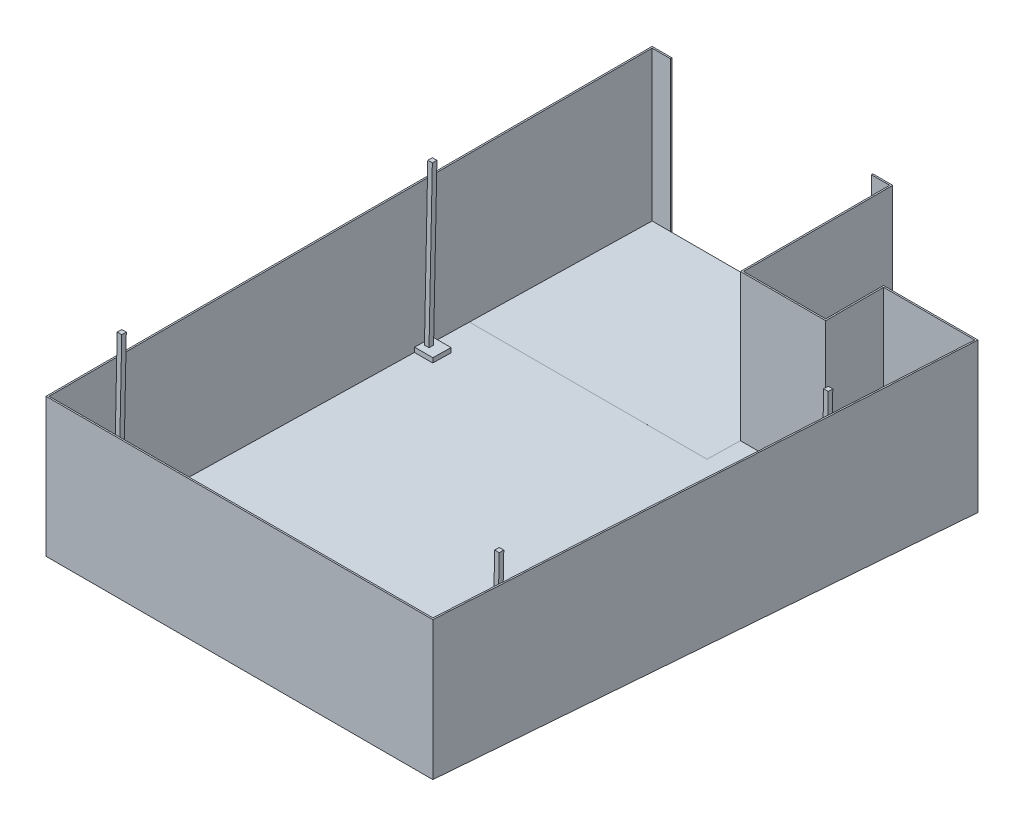
from build123d import *

# Parameters (mm, degrees)
BOSS_EXTRUDE2_DEPTH      = 2311.4
BOSS_EXTRUDE2_DEPTH_BACK = 254
CUT_EXTRUDE1_DEPTH       = 8907.603352569
SHELL3_T                 = -25.4
SKETCH5_W                = 304.8
SKETCH5_H                = 304.8
BOSS_EXTRUDE4_DEPTH      = 76.2
SKETCH6_W                = 76.2
SKETCH6_H                = 76.2
BOSS_EXTRUDE6_DEPTH      = 2643.378
BOSS_EXTRUDE7_DEPTH      = 0.0254
SKETCH8_W                = 3352.8
SKETCH8_H                = 2523.157553015
CUT_EXTRUDE2_DEPTH       = 25.4


with BuildPart() as part:
    # Sketch2 → Boss-Extrude2 (new, two sides)
    with BuildSketch(Plane(origin=(0, 0, 0), x_dir=(1, 0, 0), z_dir=(0, 1, 0))) as boss_extrude2_sk:
        Polygon((0, 5054.6), (0, -5054.6), (6451.6, -5054.6), (6959.6, 3530.6), (5384.8, 3530.6), (5384.8, 2565.4), (4013.2, 2565.4), (4013.2, 5054.6), align=None)
    extrude(amount=BOSS_EXTRUDE2_DEPTH)
    extrude(boss_extrude2_sk.sketch, amount=-BOSS_EXTRUDE2_DEPTH_BACK)

    # Sketch4 → Cut-Extrude1 (cut, through all)
    with BuildSketch(Plane.ZY):
        Polygon((5054.6, 0), (-5054.6, -211.757553015), (-5054.6, -254), (5054.6, -254), align=None)
    extrude(amount=-CUT_EXTRUDE1_DEPTH, mode=Mode.SUBTRACT)

    # Shell3
    shell3_openings = [part.faces().sort_by_distance(p)[0] for p in [
        (3193.672214635, 2311.4, 297.114656183),
    ]]
    offset(amount=SHELL3_T, openings=shell3_openings, kind=Kind.INTERSECTION)

    # Sketch5 → Boss-Extrude4 (add)
    with BuildSketch(Plane(origin=(0, -80.43791031, 1.684934026), x_dir=(1, 0, 0), z_dir=(0, 0.9997806834748456, -0.020942419883350005))):
        with Locations((177.8, -3961.817924984)):
            Rectangle(SKETCH5_W, SKETCH5_H)
        with Locations((177.8, 1219.782075016)):
            Rectangle(SKETCH5_W, SKETCH5_H)
        Polygon((6501.521028173, 1067.382075016), (6788.289480699, 1067.382075016), (6806.321028173, 1372.182075016), (6501.521028173, 1372.182075016), align=None)
        Polygon((6194.451826209, -4114.217924984), (6481.753173628, -4114.217924984), (6499.784721103, -3809.417924984), (6194.451826209, -3809.417924984), align=None)
    extrude(amount=BOSS_EXTRUDE4_DEPTH)

    # Sketch6 → Boss-Extrude6 (add)
    with BuildSketch(Plane(origin=(0, -4.254622229, 0.089121631), x_dir=(1, 0, 0), z_dir=(0, 0.9997806834748456, -0.02094241988335002))):
        with Locations((114.3, 1219.782075016)):
            Rectangle(SKETCH6_W, SKETCH6_H)
        with Locations((114.3, -3961.817924984)):
            Rectangle(SKETCH6_W, SKETCH6_H)
        with Locations((6410.351826209, -3961.817924984)):
            Rectangle(SKETCH6_W, SKETCH6_H)
        with Locations((6717.421028173, 1219.782075016)):
            Rectangle(SKETCH6_W, SKETCH6_H)
    extrude(amount=BOSS_EXTRUDE6_DEPTH)

    # Sketch7 → Boss-Extrude7 (add)
    with BuildSketch(Plane(origin=(0, -80.43791031, 1.684934026), x_dir=(1, 0, 0), z_dir=(0, 0.9997806834748456, -0.020942419883350005))):
        Polygon((0, 1983.988532266), (3987.8, 1983.988532266), (3987.8, 5031.988532266), (25.4, 5031.988532266), align=None)
    extrude(amount=BOSS_EXTRUDE7_DEPTH)

    # Sketch8 → Cut-Extrude2 (cut)
    with BuildSketch(Plane(origin=(0, 0, -5054.6), x_dir=(-1, 0, 0), z_dir=(0, 0, -1))):
        with Locations((-2006.6, 1049.821223492)):
            Rectangle(SKETCH8_W, SKETCH8_H)
    extrude(amount=-CUT_EXTRUDE2_DEPTH, mode=Mode.SUBTRACT)


solid = part.part
